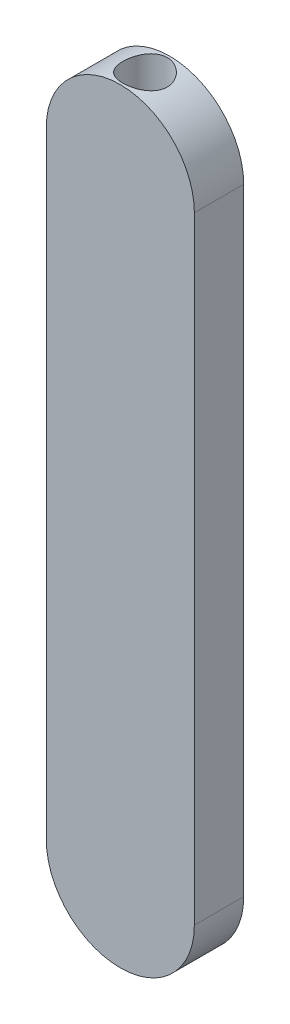
from build123d import *

# Parameters (mm, degrees)
BOSS_EXTRUDE1_DEPTH = 10
SKETCH5_R           = 9
CUT_EXTRUDE1_DEPTH  = 40


with BuildPart() as part:
    # Sketch3 → Boss-Extrude1 (new body, symmetric)
    with BuildSketch(Plane.XY):
        with BuildLine():
            Line((-30, -125), (-30, 125))
            ThreePointArc((-30, 125), (0, 155), (30, 125))
            Line((30, 125), (30, -125))
            ThreePointArc((30, -125), (0, -155), (-30, -125))
        make_face()
    extrude(amount=BOSS_EXTRUDE1_DEPTH, both=True)

    # Sketch5 → Cut-Extrude1 (cut)
    with BuildSketch(Plane(origin=(0, 125, 0), x_dir=(1, 0, 0), z_dir=(0, 1, 0))):
        Circle(SKETCH5_R)
    extrude(amount=CUT_EXTRUDE1_DEPTH, mode=Mode.SUBTRACT)


solid = part.part
